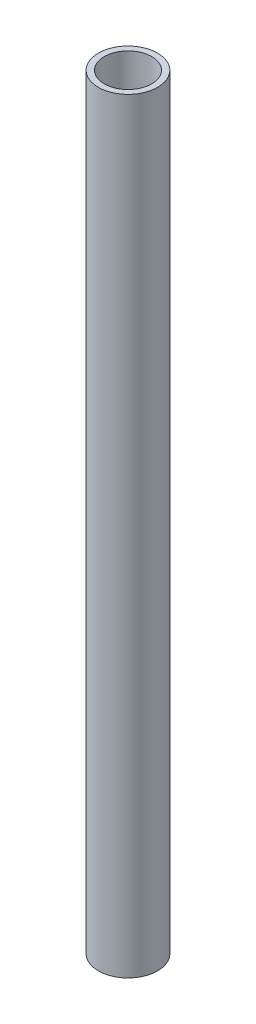
from build123d import *

# Parameters (mm, degrees)
SKETCH1_R           = 7.9375
SKETCH1_R_2         = 6.35
BOSS_EXTRUDE1_DEPTH = 205


with BuildPart() as part:
    # Sketch1 → Boss-Extrude1 (new body)
    with BuildSketch(Plane(origin=(0, 0, 0), x_dir=(1, 0, 0), z_dir=(0, 1, 0))):
        Circle(SKETCH1_R)
        Circle(SKETCH1_R_2, mode=Mode.SUBTRACT)
    extrude(amount=BOSS_EXTRUDE1_DEPTH)


solid = part.part
